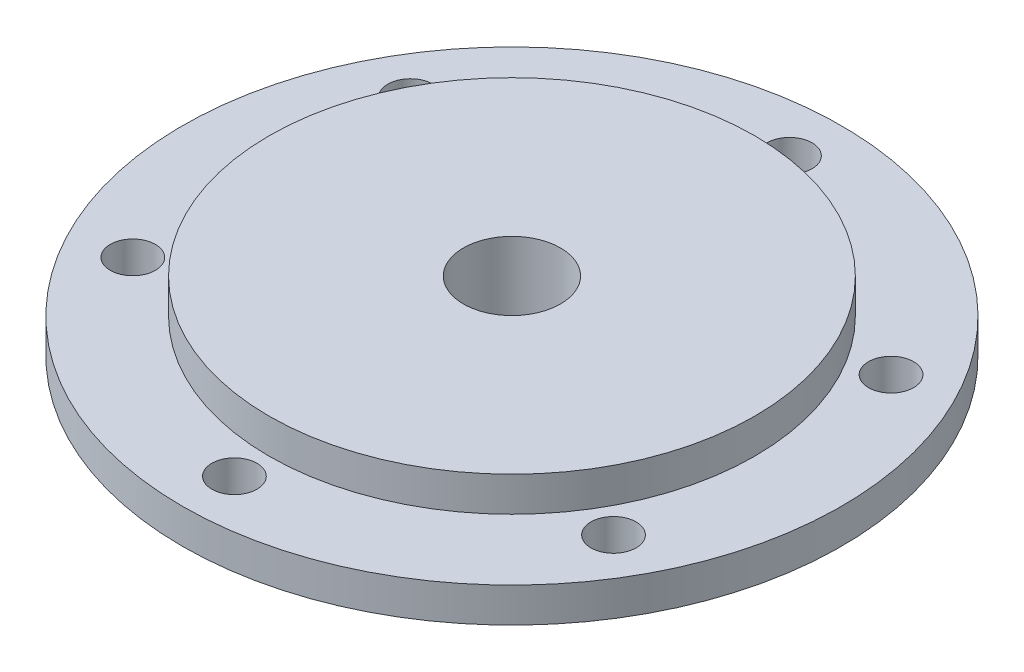
from build123d import *

# Parameters (mm, degrees)
SKETCH2_R               = 47.5
SKETCH2_R_2             = 3.25
BOSS_EXTRUDE1_DEPTH     = 2.5
SKETCH3_R               = 7
CUT_EXTRUDE1_DEPTH      = 5
SKETCH4_R               = 35
BOSS_EXTRUDE2_DEPTH     = 5
SKETCH5_R               = 14
BOSS_EXTRUDE3_DEPTH     = 18
SKETCH6_R               = 7
CUT_EXTRUDE2_DEPTH      = 1
CUT_EXTRUDE2_DEPTH_BACK = 29
FILLET1_R               = 5


with BuildPart() as part:
    # Sketch2 → Boss-Extrude1 (new body, symmetric)
    with BuildSketch(Plane(origin=(0, 0, 0), x_dir=(1, 0, 0), z_dir=(0, 1, 0))):
        Circle(SKETCH2_R)
        with Locations((0, 40)):
            Circle(SKETCH2_R_2, mode=Mode.SUBTRACT)
        with Locations((34.641016151, 20)):
            Circle(SKETCH2_R_2, mode=Mode.SUBTRACT)
        with Locations((34.641016151, -20)):
            Circle(SKETCH2_R_2, mode=Mode.SUBTRACT)
        with Locations((0, -40)):
            Circle(SKETCH2_R_2, mode=Mode.SUBTRACT)
        with Locations((-34.641016151, -20)):
            Circle(SKETCH2_R_2, mode=Mode.SUBTRACT)
        with Locations((-34.641016151, 20)):
            Circle(SKETCH2_R_2, mode=Mode.SUBTRACT)
    extrude(amount=BOSS_EXTRUDE1_DEPTH, both=True)

    # Sketch3 → Cut-Extrude1 (cut)
    with BuildSketch(Plane(origin=(0, 2.5, 0), x_dir=(1, 0, 0), z_dir=(0, 1, 0))):
        Circle(SKETCH3_R)
    extrude(amount=-CUT_EXTRUDE1_DEPTH, mode=Mode.SUBTRACT)

    # Sketch4 → Boss-Extrude2 (add)
    with BuildSketch(Plane(origin=(0, 2.5, 0), x_dir=(1, 0, 0), z_dir=(0, 1, 0))):
        Circle(SKETCH4_R)
    extrude(amount=BOSS_EXTRUDE2_DEPTH)

    # Sketch5 → Boss-Extrude3 (add)
    with BuildSketch(Plane.XZ.offset(2.5)):
        Circle(SKETCH5_R)
    extrude(amount=BOSS_EXTRUDE3_DEPTH)

    # Sketch6 → Cut-Extrude2 (cut, two sides)
    with BuildSketch(Plane.XZ.offset(20.5)) as cut_extrude2_sk:
        Circle(SKETCH6_R)
    extrude(amount=CUT_EXTRUDE2_DEPTH, mode=Mode.SUBTRACT)
    extrude(cut_extrude2_sk.sketch, amount=-CUT_EXTRUDE2_DEPTH_BACK, mode=Mode.SUBTRACT)

    # Fillet1
    fillet1_edges = [part.edges().sort_by_distance(p)[0] for p in [
        (-14, -2.5, 0),
    ]]
    fillet(fillet1_edges, radius=FILLET1_R)


solid = part.part
